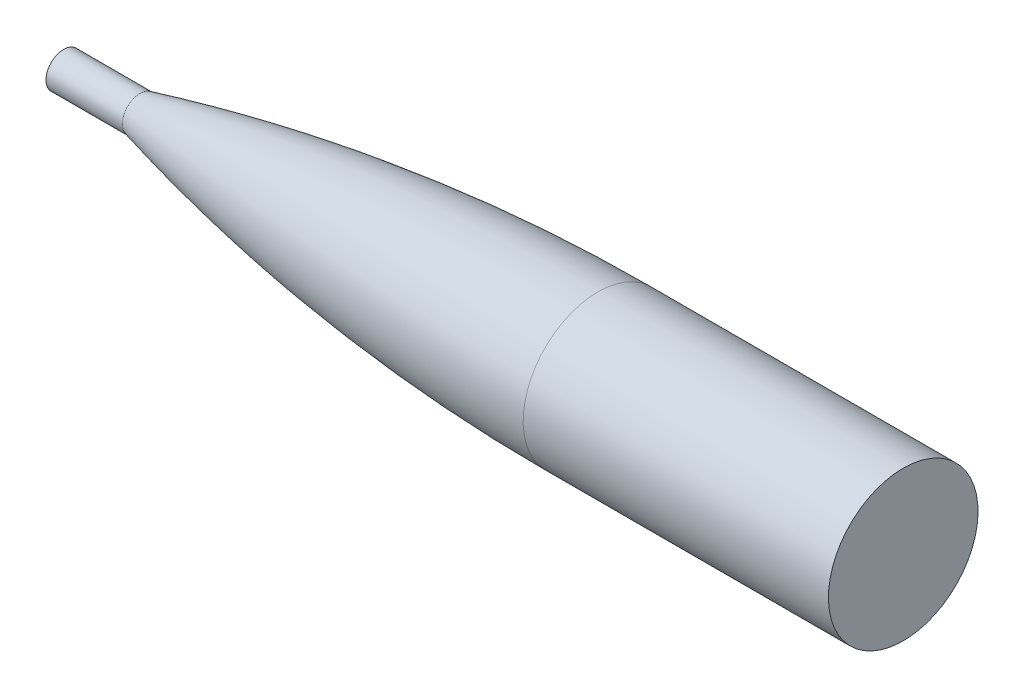
from build123d import *

# Parameters (mm, degrees)
SKETCH2_R           = 49.784
BOSS_EXTRUDE1_DEPTH = 203.2
SKETCH3_R           = 11.74839717
BOSS_EXTRUDE2_DEPTH = 50.8


with BuildPart() as part:
    # Sketch1 → Revolve1 (revolve)
    with BuildSketch(Plane.XY):
        with BuildLine():
            Line((304.8, 49.784), (304.8, 0))
            Line((304.8, 0), (0, 0))
            Line((0, 0), (0, 11.748397173))
            add(Edge.make_bspline(
                [(0, 11.748397173), (0.424160675, 11.855932678), (1.277768006, 12.07173392), (3.085410505, 12.527272667), (5.106222596, 13.032281093), (7.110128552, 13.529344024), (9.159948224, 14.034387922), (11.195444228, 14.532141119), (13.233412884, 15.026861964), (15.805049223, 15.64653599), (18.91026091, 16.387291474), (22.550652523, 17.244690048), (26.727238439, 18.213147263), (31.952168035, 19.405675489), (42.412897925, 21.742539102), (62.333903875, 25.976370199), (110.770450737, 35.225121195), (160.70732909, 42.159920913), (207.702302928, 46.434962608), (245.168015054, 48.368183749), (253.734807707, 48.740972714), (260.161369668, 48.98354131), (264.446272339, 49.130442523), (268.731666265, 49.262530797), (273.017475857, 49.379804553), (277.303691578, 49.48226239), (281.590188304, 49.569903083), (285.329649653, 49.633426545), (288.521672796, 49.67849525), (291.166731437, 49.70980578), (293.263778354, 49.731088433), (295.359186858, 49.74882407), (297.470177021, 49.76301264), (299.535126271, 49.773654103), (301.617177871, 49.780748429), (303.482211221, 49.783408805), (304.362420109, 49.784), (304.8, 49.784)],
                knots=[0.082917815, 0.082917815, 0.082917815, 0.082917815, 0.082917815, 0.088601511, 0.094285207, 0.099968902, 0.105652598, 0.111336294, 0.11701999, 0.122703686, 0.128387381, 0.140005218, 0.151623054, 0.16324089, 0.174858727, 0.198094396, 0.267801409, 0.383979763, 0.709279153, 0.744132659, 0.778986165, 0.790604, 0.802221836, 0.813839671, 0.825457507, 0.837075342, 0.848693177, 0.860311013, 0.871928848, 0.877612544, 0.883296239, 0.888979935, 0.89466363, 0.900347326, 0.906031021, 0.911714717, 0.917398412, 0.917398412, 0.917398412, 0.917398412, 0.917398412], degree=4))
        make_face()
    revolve(axis=Axis((304.8, 0, 0), (-1, 0, 0)))

    # Sketch2 → Boss-Extrude1 (add)
    with BuildSketch(Plane(origin=(304.8, 0, 0), x_dir=(0, 0, -1), z_dir=(1, 0, 0))):
        Circle(SKETCH2_R)
    extrude(amount=BOSS_EXTRUDE1_DEPTH)

    # Sketch3 → Boss-Extrude2 (add)
    with BuildSketch(Plane.ZY):
        Circle(SKETCH3_R)
    extrude(amount=BOSS_EXTRUDE2_DEPTH)


solid = part.part
